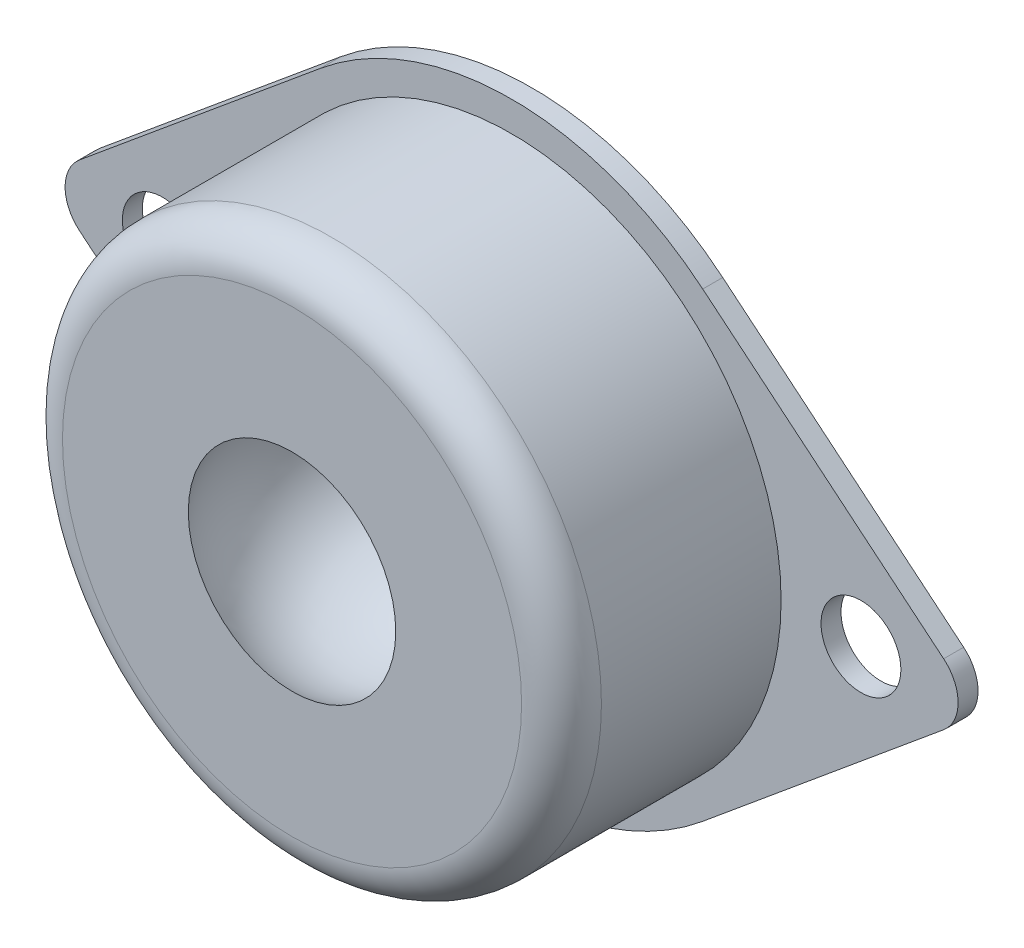
from build123d import *

# Parameters (mm, degrees)
SKETCH_1_R      = 13.5
SKETCH_1_R_2    = 2
EXTRUDE_3_DEPTH = 1
SKETCH_3_R      = 13.5
EXTRUDE_4_DEPTH = 12
FILLET_3_R      = 2


with BuildPart() as part:
    # 草图1 → 凸台-拉伸3 (new body)
    with BuildSketch(Plane.XY):
        with BuildLine():
            Line((-21.643262411, 1.539578937), (-9.574468085, 11.546842031))
            ThreePointArc((-9.574468085, 11.546842031), (0, 15), (9.574468085, 11.546842031))
            Line((9.574468085, 11.546842031), (21.643262411, 1.539578937))
            ThreePointArc((21.643262411, 1.539578937), (22.366666667, 0), (21.643262411, -1.539578937))
            Line((21.643262411, -1.539578937), (9.574468085, -11.546842031))
            ThreePointArc((9.574468085, -11.546842031), (0, -15), (-9.574468085, -11.546842031))
            Line((-9.574468085, -11.546842031), (-21.643262411, -1.539578937))
            ThreePointArc((-21.643262411, -1.539578937), (-22.366666667, 0), (-21.643262411, 1.539578937))
        make_face()
        Circle(SKETCH_1_R, mode=Mode.SUBTRACT)
        with Locations((-17.5, 0)):
            Circle(SKETCH_1_R_2, mode=Mode.SUBTRACT)
        with Locations((17.5, 0)):
            Circle(SKETCH_1_R_2, mode=Mode.SUBTRACT)
    extrude(amount=EXTRUDE_3_DEPTH)

    # 草图3 → 凸台-拉伸4 (add)
    with BuildSketch(Plane.XY):
        Circle(SKETCH_3_R)
    extrude(amount=EXTRUDE_4_DEPTH)

    # 圆角3
    fillet_3_edges = [part.edges().sort_by_distance(p)[0] for p in [
        (-13.5, 0, 12),
    ]]
    fillet(fillet_3_edges, radius=FILLET_3_R)

    # 草图4 → 切除-旋转9 (revolve, cut)
    with BuildSketch(Plane(origin=(0, 0, 0), x_dir=(1, 0, 0), z_dir=(0, 1, 0))):
        with BuildLine():
            Line((0, -12), (5.196152423, -12))
            ThreePointArc((5.196152423, -12), (5.196152423, -6), (0, -3))
            Line((0, -3), (0, -12))
        make_face()
    revolve(axis=Axis((0, 0, 0), (0, 0, 1)), mode=Mode.SUBTRACT)


solid = part.part
